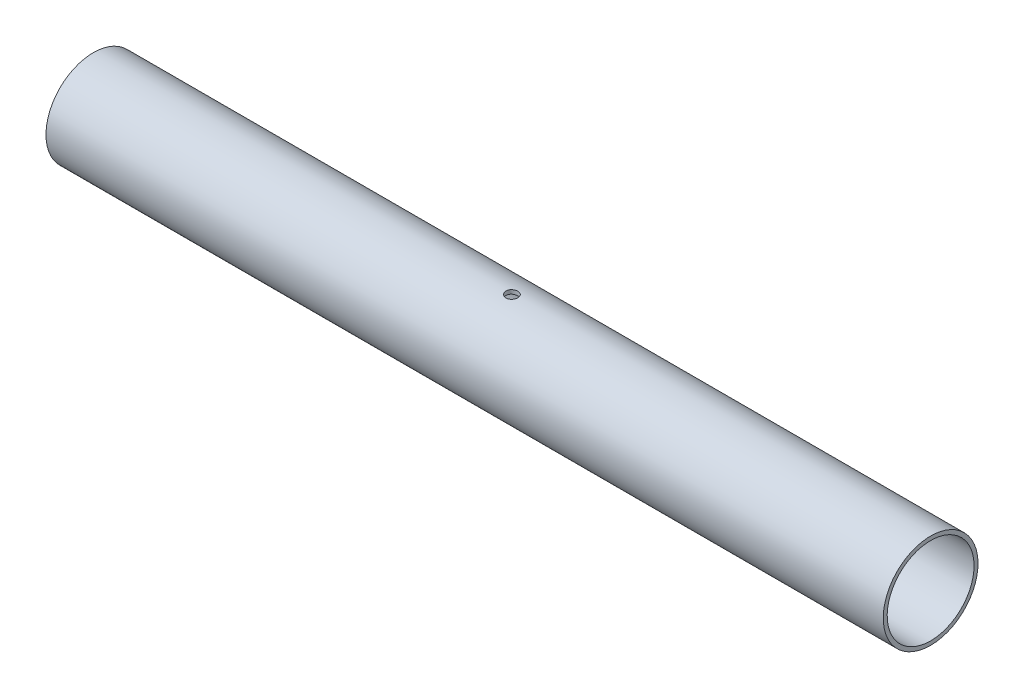
from build123d import *

# Parameters (mm, degrees)
SKETCH1_R           = 12
SKETCH1_R_2         = 11
BOSS_EXTRUDE1_DEPTH = 106
SKETCH2_R           = 1.5
CUT_EXTRUDE1_DEPTH  = 25


with BuildPart() as part:
    # Sketch1 → Boss-Extrude1 (new body, symmetric)
    with BuildSketch(Plane.ZY.offset(15.527905639)):
        with Locations((50, 105.869562716)):
            Circle(SKETCH1_R)
        with Locations((50, 105.869562716)):
            Circle(SKETCH1_R_2, mode=Mode.SUBTRACT)
    extrude(amount=BOSS_EXTRUDE1_DEPTH, both=True)

    # Sketch2 → Cut-Extrude1 (cut, through all)
    with BuildSketch(Plane(origin=(0, 117.869562716, 0), x_dir=(1, 0, 0), z_dir=(0, 1, 0))):
        with Locations((-15.527905639, -50)):
            Circle(SKETCH2_R)
    extrude(amount=-CUT_EXTRUDE1_DEPTH, mode=Mode.SUBTRACT)


solid = part.part
